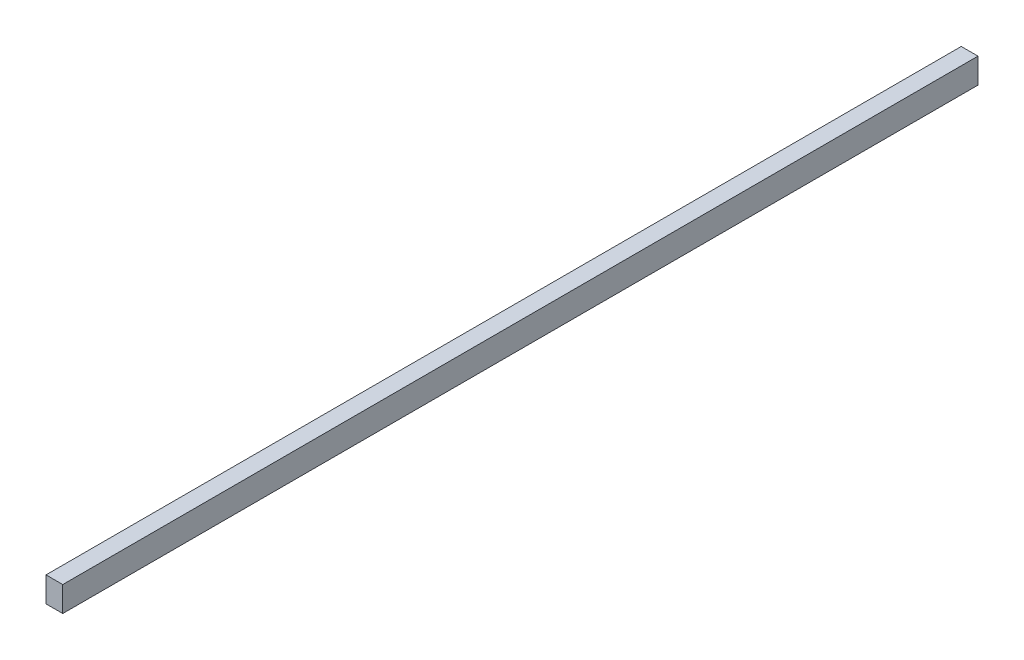
from build123d import *

# Parameters (mm, degrees)
ESQUISSE2_W        = 20
ESQUISSE2_H        = 1093
BOSS_EXTRU_1_DEPTH = 30


with BuildPart() as part:
    # Esquisse2 → Boss.-Extru.1 (new body)
    with BuildSketch(Plane(origin=(0, -21.5, 0), x_dir=(1, 0, 0), z_dir=(0, 1, 0))):
        with Locations((-251, -546.5)):
            Rectangle(ESQUISSE2_W, ESQUISSE2_H)
    extrude(amount=BOSS_EXTRU_1_DEPTH)


solid = part.part
